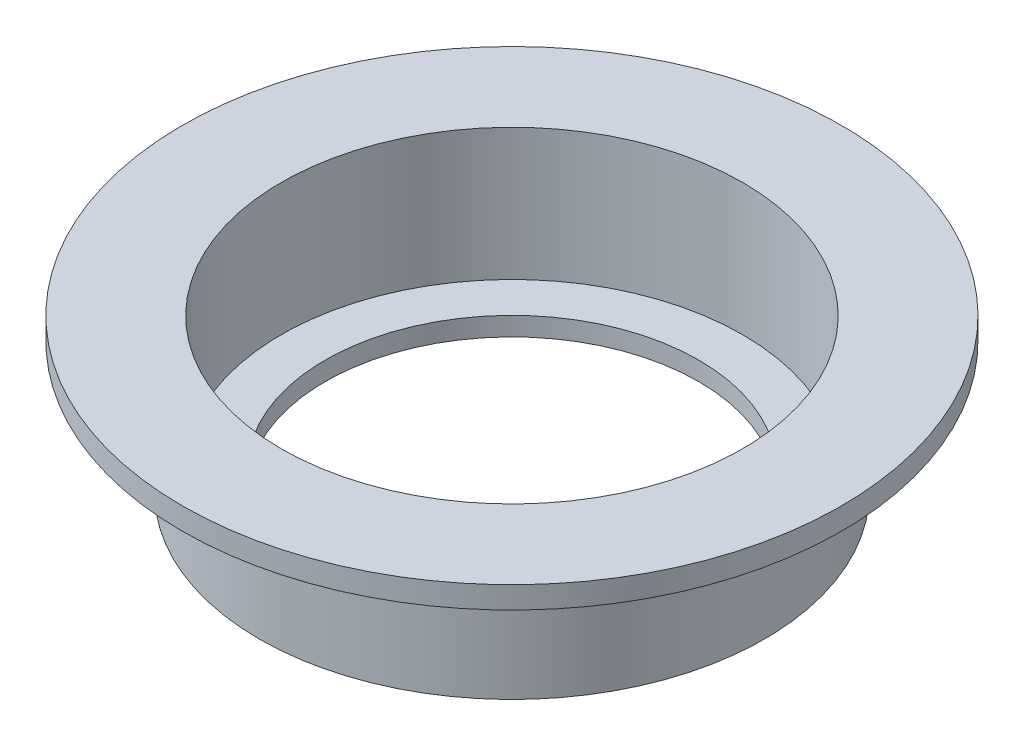
from build123d import *


with BuildPart() as part:
    # Sketch1 → Revolve1 (revolve)
    with BuildSketch(Plane.XY):
        Polygon((15, 3.175), (10.5, 3.175), (10.5, -2.825), (8.5, -2.825), (8.5, -3.675), (10.5, -3.675), (10.5, -3.825), (11.5, -3.825), (11.5, 2.175), (15, 2.175), align=None)
    revolve(axis=Axis((0, 11.223214286, 0), (0, -1, 0)))


solid = part.part
